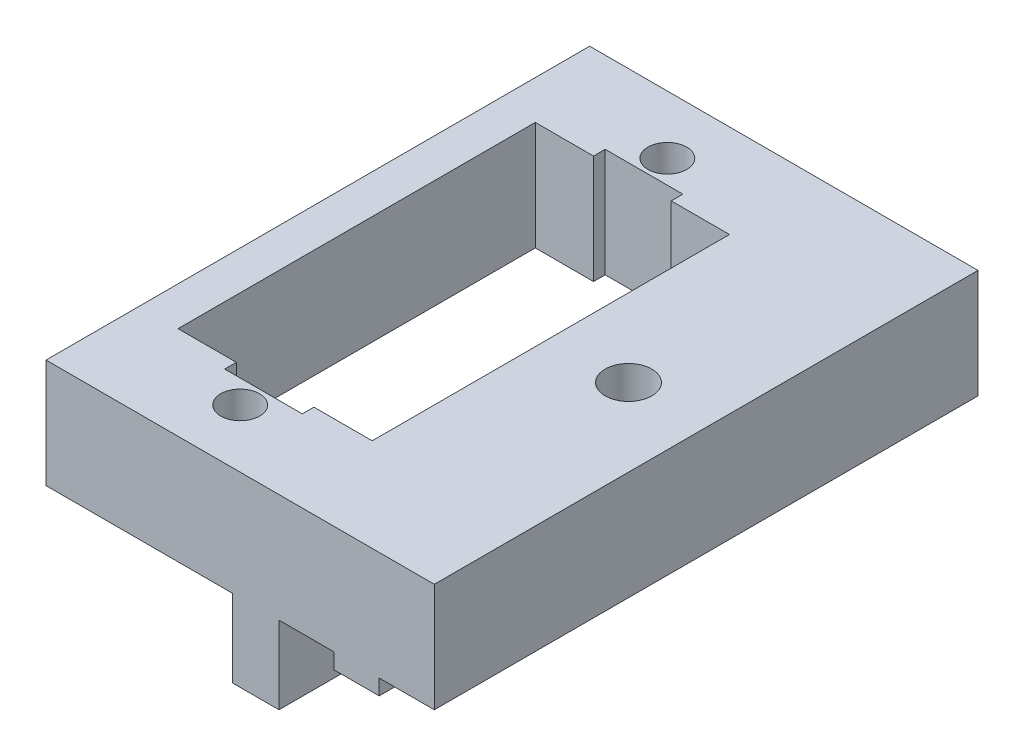
from build123d import *

# Parameters (mm, degrees)
MAIN_DEPTH            = 17.5
SKETCH2_R             = 1.5
SKETCH2_R_2           = 1.25
FIXINGHOLE_DEPTH      = 13
SKETCH3_W             = 12.5
SKETCH3_H             = 23
SERVOSQUAREHOLE_DEPTH = 13
SKETCH4_W             = 5
SKETCH4_H             = 24.5
CABLEHOLE_DEPTH       = 13


with BuildPart() as part:
    # Sketch1 → Main (new body, symmetric)
    with BuildSketch(Plane.XY):
        Polygon((10, 0), (10, 7), (-15, 7), (-15, 0), (-3, 0), (-3, -5), (0, -5), (0, 0), (3.55, 0), (3.55, -1), (6.45, -1), (6.45, 0), align=None)
    extrude(amount=MAIN_DEPTH, both=True)

    # Sketch2 → FixingHole (cut, through all)
    with BuildSketch(Plane(origin=(0, 7, 0), x_dir=(1, 0, 0), z_dir=(0, 1, 0))):
        with Locations((5, 0)):
            Circle(SKETCH2_R)
        with Locations((-6.25, 13.75)):
            Circle(SKETCH2_R_2)
        with Locations((-6.25, -13.75)):
            Circle(SKETCH2_R_2)
    extrude(amount=-FIXINGHOLE_DEPTH, mode=Mode.SUBTRACT)

    # Sketch3 → ServoSquareHole (cut, through all)
    with BuildSketch(Plane(origin=(0, 7, 0), x_dir=(1, 0, 0), z_dir=(0, 1, 0))):
        with Locations((-6.25, 0)):
            Rectangle(SKETCH3_W, SKETCH3_H)
    extrude(amount=-SERVOSQUAREHOLE_DEPTH, mode=Mode.SUBTRACT)

    # Sketch4 → CableHole (cut, through all)
    with BuildSketch(Plane(origin=(0, 7, 0), x_dir=(1, 0, 0), z_dir=(0, 1, 0))):
        with Locations((-6.25, 0)):
            Rectangle(SKETCH4_W, SKETCH4_H)
    extrude(amount=-CABLEHOLE_DEPTH, mode=Mode.SUBTRACT)


solid = part.part
